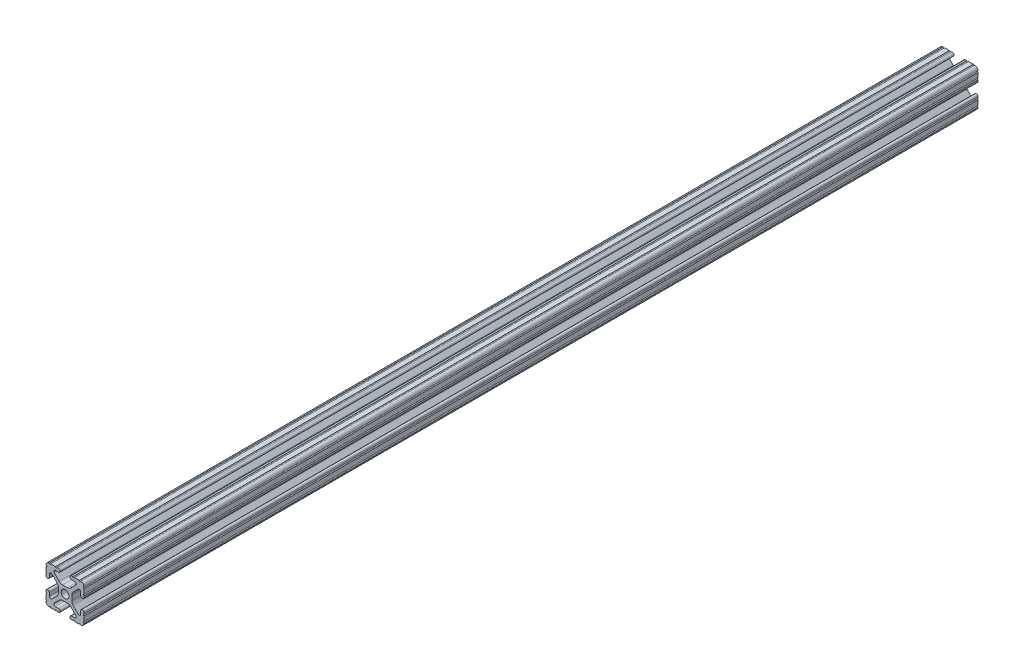
from build123d import *

# Parameters (mm, degrees)
SKETCH1_R           = 2.6035
BOSS_EXTRUDE1_DEPTH = 596.9


with BuildPart() as part:
    # Sketch1 → Boss-Extrude1 (new body)
    with BuildSketch(Plane.XY):
        with BuildLine():
            Line((-12.7, 9.5504), (-12.7, 6.3330836))
            ThreePointArc((-12.7, 6.3330836), (-12.191999975, 5.8250836), (-12.7, 5.3170836))
            Line((-12.7, 5.3170836), (-12.7, 4.3434))
            ThreePointArc((-12.7, 4.3434), (-11.5951, 3.238499971), (-10.4902, 4.3434))
            Line((-10.4902, 4.3434), (-10.4902, 6.474794456))
            ThreePointArc((-10.4902, 6.474794456), (-9.863006367, 7.413456061), (-8.75577951, 7.193214945))
            Line((-8.75577951, 7.193214945), (-5.42573597, 3.863171405))
            ThreePointArc((-5.42573597, 3.863171405), (-4.737482484, 2.833127272), (-4.4958, 1.618107374))
            Line((-4.4958, 1.618107374), (-4.4958, -1.618107374))
            ThreePointArc((-4.4958, -1.618107374), (-4.737482484, -2.833127272), (-5.42573597, -3.863171405))
            Line((-5.42573597, -3.863171405), (-8.75577951, -7.193214945))
            ThreePointArc((-8.75577951, -7.193214945), (-9.863006367, -7.413456061), (-10.4902, -6.474794456))
            Line((-10.4902, -6.474794456), (-10.4902, -4.3434))
            ThreePointArc((-10.4902, -4.3434), (-11.5951, -3.2385), (-12.7, -4.3434))
            Line((-12.7, -4.3434), (-12.7, -5.3170836))
            ThreePointArc((-12.7, -5.3170836), (-12.191999983, -5.8250836), (-12.7, -6.3330836))
            Line((-12.7, -6.3330836), (-12.7, -9.5504))
            ThreePointArc((-12.7, -9.5504), (-12.192000006, -10.058323491), (-12.699846982, -10.566399977))
            ThreePointArc((-12.699846982, -10.566399977), (-12.082522516, -12.082522516), (-10.566399977, -12.699846982))
            ThreePointArc((-10.566399977, -12.699846982), (-10.058323491, -12.192000006), (-9.5504, -12.7))
            Line((-9.5504, -12.7), (-6.3330836, -12.7))
            ThreePointArc((-6.3330836, -12.7), (-5.8250836, -12.191999983), (-5.3170836, -12.7))
            Line((-5.3170836, -12.7), (-4.3434, -12.7))
            ThreePointArc((-4.3434, -12.7), (-3.238499971, -11.5951), (-4.3434, -10.4902))
            Line((-4.3434, -10.4902), (-6.474794456, -10.4902))
            ThreePointArc((-6.474794456, -10.4902), (-7.413456061, -9.863006367), (-7.193214945, -8.75577951))
            Line((-7.193214945, -8.75577951), (-3.863171405, -5.42573597))
            ThreePointArc((-3.863171405, -5.42573597), (-2.833127272, -4.737482484), (-1.618107374, -4.4958))
            Line((-1.618107374, -4.4958), (1.618107374, -4.4958))
            ThreePointArc((1.618107374, -4.4958), (2.833127272, -4.737482484), (3.863171405, -5.42573597))
            Line((3.863171405, -5.42573597), (7.193214945, -8.75577951))
            ThreePointArc((7.193214945, -8.75577951), (7.413456061, -9.863006367), (6.474794456, -10.4902))
            Line((6.474794456, -10.4902), (4.3434, -10.4902))
            ThreePointArc((4.3434, -10.4902), (3.2385, -11.5951), (4.3434, -12.7))
            Line((4.3434, -12.7), (5.3170836, -12.7))
            ThreePointArc((5.3170836, -12.7), (5.8250836, -12.191999983), (6.3330836, -12.7))
            Line((6.3330836, -12.7), (9.5504, -12.7))
            ThreePointArc((9.5504, -12.7), (10.058323491, -12.192000006), (10.566399977, -12.699846982))
            ThreePointArc((10.566399977, -12.699846982), (12.082522516, -12.082522516), (12.699846982, -10.566399977))
            ThreePointArc((12.699846982, -10.566399977), (12.192000006, -10.058323491), (12.7, -9.5504))
            Line((12.7, -9.5504), (12.7, -6.3330836))
            ThreePointArc((12.7, -6.3330836), (12.191999983, -5.8250836), (12.7, -5.3170836))
            Line((12.7, -5.3170836), (12.7, -4.3434))
            ThreePointArc((12.7, -4.3434), (11.5951, -3.238499971), (10.4902, -4.3434))
            Line((10.4902, -4.3434), (10.4902, -6.474794456))
            ThreePointArc((10.4902, -6.474794456), (9.863006367, -7.413456061), (8.75577951, -7.193214945))
            Line((8.75577951, -7.193214945), (5.42573597, -3.863171405))
            ThreePointArc((5.42573597, -3.863171405), (4.737482484, -2.833127272), (4.4958, -1.618107374))
            Line((4.4958, -1.618107374), (4.4958, 1.618107374))
            ThreePointArc((4.4958, 1.618107374), (4.737482484, 2.833127272), (5.42573597, 3.863171405))
            Line((5.42573597, 3.863171405), (8.75577951, 7.193214945))
            ThreePointArc((8.75577951, 7.193214945), (9.863006367, 7.413456061), (10.4902, 6.474794456))
            Line((10.4902, 6.474794456), (10.4902, 4.3434))
            ThreePointArc((10.4902, 4.3434), (11.5951, 3.2385), (12.7, 4.3434))
            Line((12.7, 4.3434), (12.7, 5.3170836))
            ThreePointArc((12.7, 5.3170836), (12.191999983, 5.8250836), (12.7, 6.3330836))
            Line((12.7, 6.3330836), (12.7, 9.5504))
            ThreePointArc((12.7, 9.5504), (12.192000006, 10.058323491), (12.699846982, 10.566399977))
            ThreePointArc((12.699846982, 10.566399977), (12.082522516, 12.082522516), (10.566399977, 12.699846982))
            ThreePointArc((10.566399977, 12.699846982), (10.058323491, 12.192000006), (9.5504, 12.7))
            Line((9.5504, 12.7), (6.3330836, 12.7))
            ThreePointArc((6.3330836, 12.7), (5.8250836, 12.192), (5.3170836, 12.7))
            Line((5.3170836, 12.7), (4.3434, 12.7))
            ThreePointArc((4.3434, 12.7), (3.238499971, 11.5951), (4.3434, 10.4902))
            Line((4.3434, 10.4902), (6.474794456, 10.4902))
            ThreePointArc((6.474794456, 10.4902), (7.413456061, 9.863006367), (7.193214945, 8.75577951))
            Line((7.193214945, 8.75577951), (3.863171405, 5.42573597))
            ThreePointArc((3.863171405, 5.42573597), (2.833127272, 4.737482484), (1.618107374, 4.4958))
            Line((1.618107374, 4.4958), (-1.618107374, 4.4958))
            ThreePointArc((-1.618107374, 4.4958), (-2.833127272, 4.737482484), (-3.863171405, 5.42573597))
            Line((-3.863171405, 5.42573597), (-7.193214945, 8.75577951))
            ThreePointArc((-7.193214945, 8.75577951), (-7.413456061, 9.863006367), (-6.474794456, 10.4902))
            Line((-6.474794456, 10.4902), (-4.3434, 10.4902))
            ThreePointArc((-4.3434, 10.4902), (-3.2385, 11.5951), (-4.3434, 12.7))
            Line((-4.3434, 12.7), (-5.3170836, 12.7))
            ThreePointArc((-5.3170836, 12.7), (-5.8250836, 12.191999983), (-6.3330836, 12.7))
            Line((-6.3330836, 12.7), (-9.5504, 12.7))
            ThreePointArc((-9.5504, 12.7), (-10.058323491, 12.192000006), (-10.566399977, 12.699846982))
            ThreePointArc((-10.566399977, 12.699846982), (-12.082522516, 12.082522516), (-12.699846982, 10.566399977))
            ThreePointArc((-12.699846982, 10.566399977), (-12.192000006, 10.058323491), (-12.7, 9.5504))
        make_face()
        Circle(SKETCH1_R, mode=Mode.SUBTRACT)
    extrude(amount=-BOSS_EXTRUDE1_DEPTH)


solid = part.part
